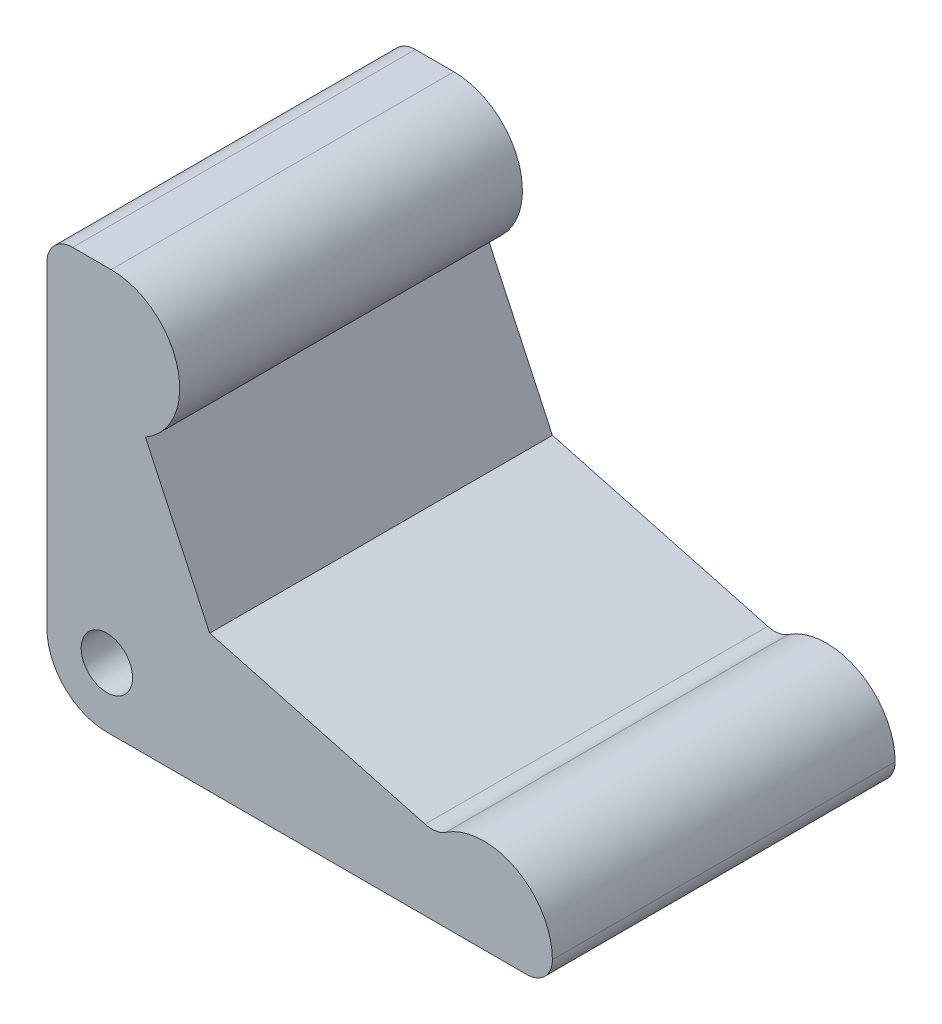
from build123d import *

# Parameters (mm, degrees)
SKETCH_1_R          = 3
EXTRUDE_1_DEPTH     = 20
SKETCH_2_R          = 7
CUT_EXTRUDE_1_DEPTH = 4


with BuildPart() as part:
    # 스케치1 → 보스-돌출1 (new body, symmetric)
    with BuildSketch(Plane.XY):
        with BuildLine():
            Line((0, 7), (0, 44))
            ThreePointArc((0, 44), (0.878679656, 46.121320344), (3, 47))
            Line((3, 47), (7.5, 47))
            ThreePointArc((7.5, 47), (15.226747122, 41.07301204), (11.504409953, 32.074344729))
            Line((11.504409953, 32.074344729), (19, 16))
            Line((19, 16), (44.136675312, 9.26464815))
            ThreePointArc((44.136675312, 9.26464815), (45.397872906, 9.201846853), (46.573187235, 9.663582275))
            ThreePointArc((46.573187235, 9.663582275), (54.780575213, 10.050336947), (59, 3))
            ThreePointArc((59, 3), (58.121320344, 0.878679656), (56, 0))
            Line((56, 0), (7, 0))
            ThreePointArc((7, 0), (2.050252532, 2.050252532), (0, 7))
        make_face()
        with Locations((7, 7)):
            Circle(SKETCH_1_R, mode=Mode.SUBTRACT)
    extrude(amount=EXTRUDE_1_DEPTH, both=True)

    # 스케치2 → 컷-돌출1 (cut)
    with BuildSketch(Plane.XZ):
        with Locations((49, 0)):
            Circle(SKETCH_2_R)
    extrude(amount=-CUT_EXTRUDE_1_DEPTH, mode=Mode.SUBTRACT)


solid = part.part
